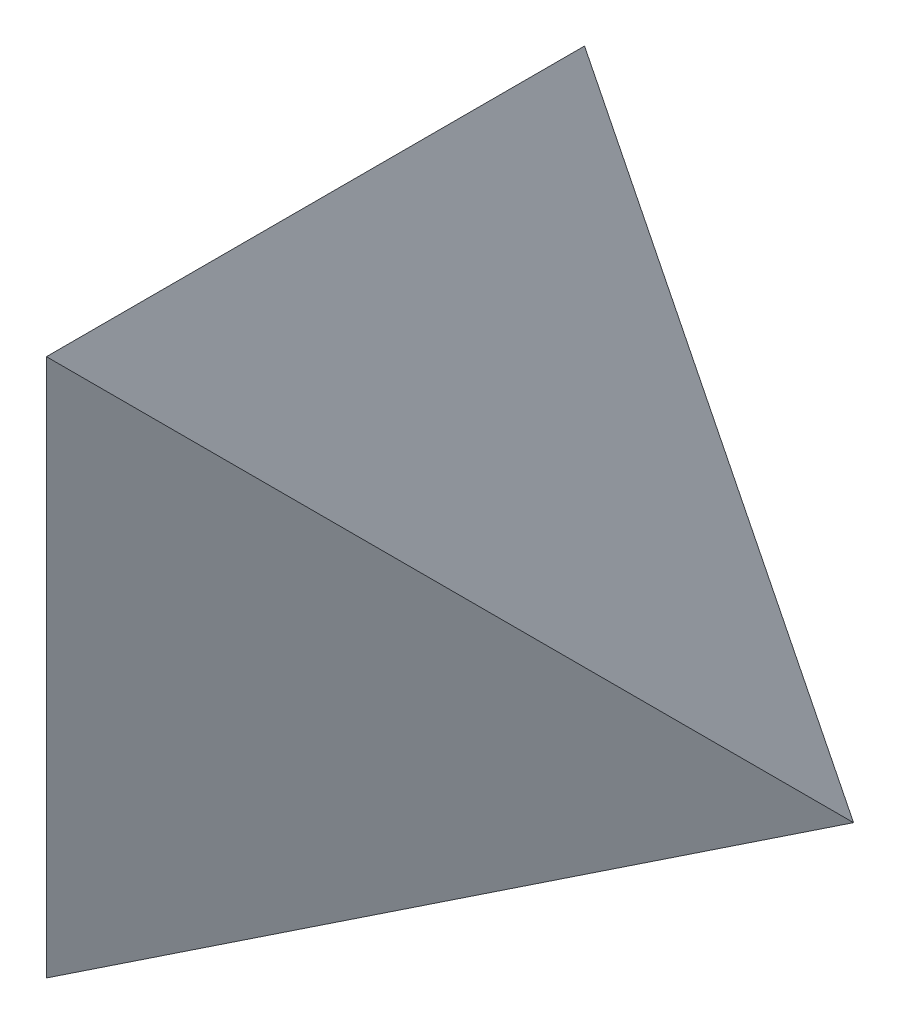
from build123d import *

# Parameters (mm, degrees)
SKETCH1_W           = 4
SKETCH1_H           = 4
BOSS_EXTRUDE1_DEPTH = 4
CUT_EXTRUDE1_DEPTH  = 10
CUT_EXTRUDE2_DEPTH  = 10
CUT_EXTRUDE3_DEPTH  = 10


with BuildPart() as part:
    # Sketch1 → Boss-Extrude1 (new body)
    with BuildSketch(Plane(origin=(0, 0, 0), x_dir=(1, 0, 0), z_dir=(0, 1, 0))):
        Rectangle(SKETCH1_W, SKETCH1_H)
    extrude(amount=BOSS_EXTRUDE1_DEPTH)

    # 3DSketch1 → Cut-Extrude1 (cut, along a direction that is not the sketch's normal)
    with BuildSketch(Plane(origin=(0, 4, -2), x_dir=(0, -0.7071067811865476, 0.7071067811865476), z_dir=(0.816496580927726, -0.408248290463863, -0.408248290463863))):
        Polygon((0, 0), (2.828427125, 3.464101615), (5.656854249, 0), align=None)
    extrude(amount=-CUT_EXTRUDE1_DEPTH, dir=(0, -1, 0), mode=Mode.SUBTRACT)


with BuildPart() as body_2:
    # of the pieces the cut leaves, the one that is kept (cut_extrude1_keep)
    add(part.part.solids().sort_by_distance((2, 0, 2))[0])

    # Sketch2 → Cut-Extrude2 (cut)
    with BuildSketch(Plane.XY.offset(2)):
        Polygon((0, 4), (2, 0), (2, 4), align=None)
    extrude(amount=-CUT_EXTRUDE2_DEPTH, mode=Mode.SUBTRACT)

    # Sketch3 → Cut-Extrude3 (cut)
    with BuildSketch(Plane.XZ):
        Polygon((0, 2), (2, -2), (2, 2), align=None)
    extrude(amount=-CUT_EXTRUDE3_DEPTH, mode=Mode.SUBTRACT)


solid = body_2.part
